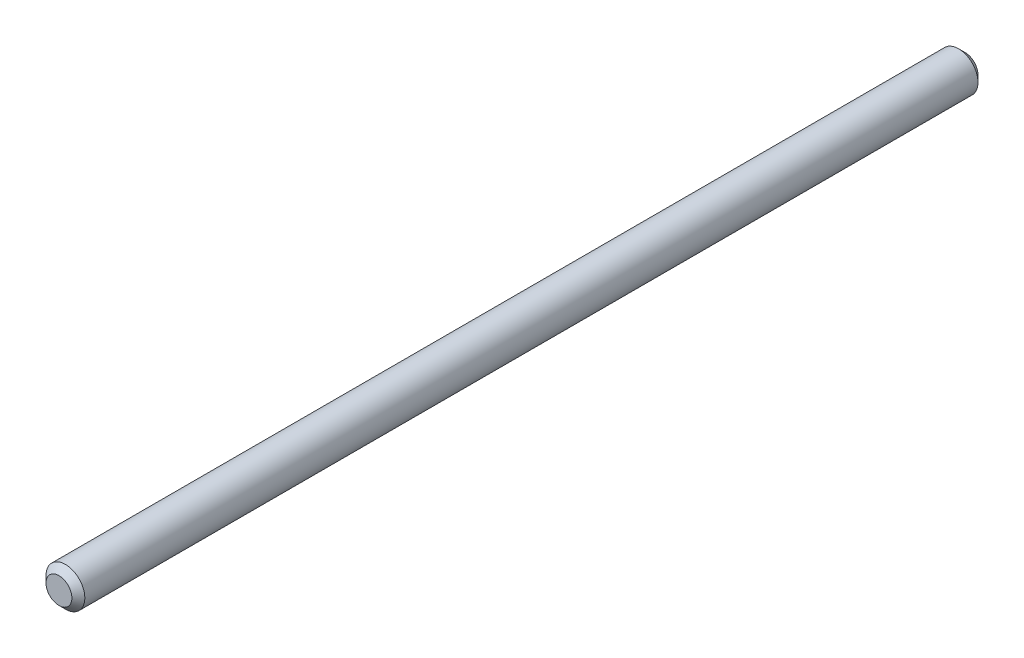
from build123d import *

# Parameters (mm, degrees)
SKETCH1_R           = 1.5
BOSS_EXTRUDE1_DEPTH = 70
CHAMFER1_SIZE       = 0.5


with BuildPart() as part:
    # Sketch1 → Boss-Extrude1 (new body)
    with BuildSketch(Plane.XY):
        Circle(SKETCH1_R)
    extrude(amount=-BOSS_EXTRUDE1_DEPTH)

    # Chamfer1
    chamfer1_edges = [part.edges().sort_by_distance(p)[0] for p in [
        (-1.5, 0, 0),
        (-1.5, 0, -70),
    ]]
    chamfer(chamfer1_edges, length=CHAMFER1_SIZE)


solid = part.part
